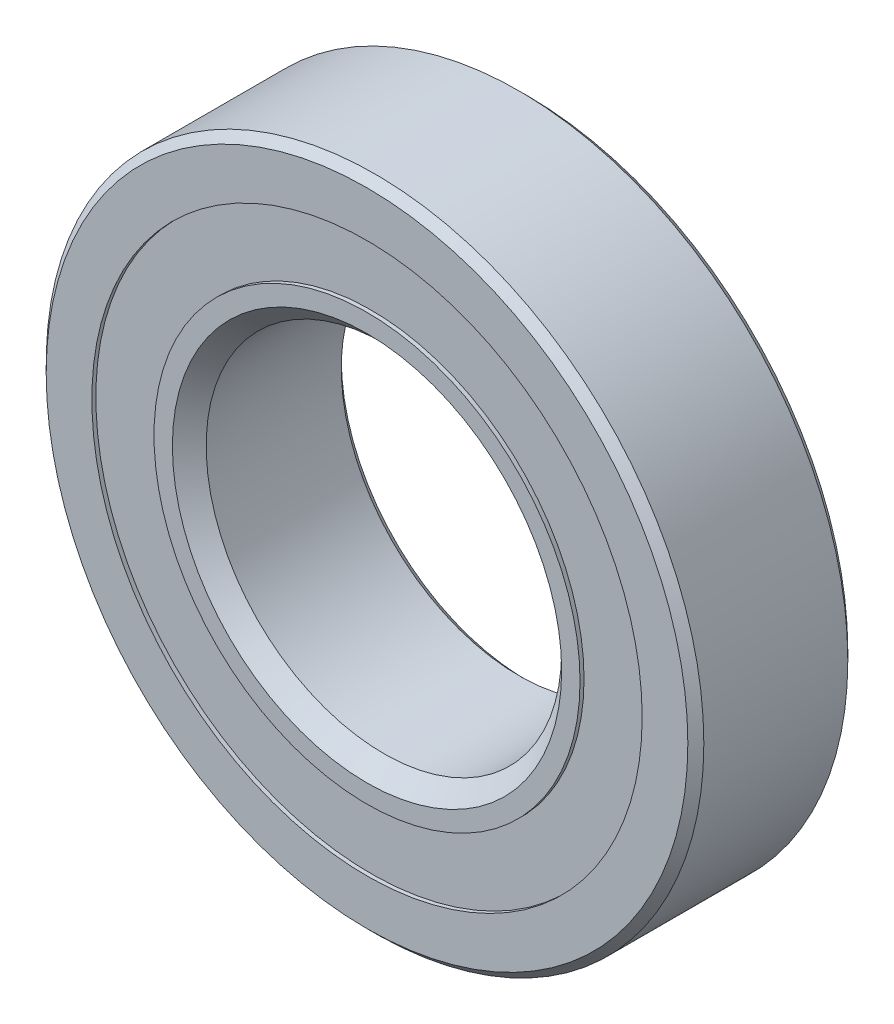
from build123d import *

# Parameters (mm, degrees)
CIRPATTERN1_COUNT = 12
SKETCH5_W         = 1.926640381
SKETCH5_H         = 3.495743751


with BuildPart() as part:
    # Sketch1 → Revolve1 (revolve)
    with BuildSketch(Plane(origin=(0, 0, 0), x_dir=(0, 0, -1), z_dir=(1, 0, 0))):
        with BuildLine():
            Line((4.05, 18.5), (-4.05, 18.5))
            Line((-4.05, 18.5), (-4.5, 18.05))
            Line((-4.5, 18.05), (-4.5, 15.480769231))
            Line((-4.5, 15.480769231), (-2, 15.480769231))
            ThreePointArc((-2, 15.480769231), (0, 16.598359619), (2, 15.480769231))
            Line((2, 15.480769231), (4.5, 15.480769231))
            Line((4.5, 15.480769231), (4.5, 18.05))
            Line((4.5, 18.05), (4.05, 18.5))
        make_face()
    revolve(axis=Axis((0, 0, 4.5), (0, 0, -1)))


with BuildPart() as body_2:
    # Sketch3 → Revolve3 (revolve)
    with BuildSketch(Plane(origin=(0, 0, 0), x_dir=(0, 0, -1), z_dir=(1, 0, 0))):
        with BuildLine():
            Line((-4.275, 11.76002548), (-3.465794711, 10.950820191))
            Line((-3.465794711, 10.950820191), (0, 10.950820191))
            Line((0, 10.950820191), (0, 11.901640381))
            ThreePointArc((0, 11.901640381), (1.145535713, 12.199990041), (2, 13.019230769))
            Line((2, 13.019230769), (4.5, 13.019230769))
            Line((4.5, 13.019230769), (4.5, 10.45))
            Line((4.5, 10.45), (4.05, 10))
            Line((4.05, 10), (-3.549179809, 10))
            Line((-3.549179809, 10), (-4.5, 10.950820191))
            Line((-4.5, 10.950820191), (-4.5, 11.98502548))
            Line((-4.5, 11.98502548), (-4.275, 11.98502548))
            Line((-4.275, 11.98502548), (-4.275, 11.76002548))
        make_face()
    revolve(axis=Axis((0, 0, 4.5), (0, 0, -1)))


with BuildPart() as body_3:
    # Sketch4 → Revolve4 (revolve)
    with BuildSketch(Plane(origin=(0, 0, 0), x_dir=(0, 0, -1), z_dir=(1, 0, 0))):
        with BuildLine():
            Line((-2.348359619, 14.25), (2.348359619, 14.25))
            ThreePointArc((2.348359619, 14.25), (0, 16.598359619), (-2.348359619, 14.25))
        make_face()
    revolve(axis=Axis((0, 14.25, 2.348359619), (0, 0, -1)))


with BuildPart() as cirpattern1_1:
    # CirPattern1: pattern copy
    add(body_3.part.rotate(Axis((0, 0, -4.5), (0, 0, 1)), 1 * 360 / CIRPATTERN1_COUNT))


with BuildPart() as cirpattern1_2:
    # CirPattern1: pattern copy
    add(body_3.part.rotate(Axis((0, 0, -4.5), (0, 0, 1)), 2 * 360 / CIRPATTERN1_COUNT))


with BuildPart() as cirpattern1_3:
    # CirPattern1: pattern copy
    add(body_3.part.rotate(Axis((0, 0, -4.5), (0, 0, 1)), 3 * 360 / CIRPATTERN1_COUNT))


with BuildPart() as cirpattern1_4:
    # CirPattern1: pattern copy
    add(body_3.part.rotate(Axis((0, 0, -4.5), (0, 0, 1)), 4 * 360 / CIRPATTERN1_COUNT))


with BuildPart() as cirpattern1_5:
    # CirPattern1: pattern copy
    add(body_3.part.rotate(Axis((0, 0, -4.5), (0, 0, 1)), 5 * 360 / CIRPATTERN1_COUNT))


with BuildPart() as cirpattern1_6:
    # CirPattern1: pattern copy
    add(body_3.part.rotate(Axis((0, 0, -4.5), (0, 0, 1)), 6 * 360 / CIRPATTERN1_COUNT))


with BuildPart() as cirpattern1_7:
    # CirPattern1: pattern copy
    add(body_3.part.rotate(Axis((0, 0, -4.5), (0, 0, 1)), 7 * 360 / CIRPATTERN1_COUNT))


with BuildPart() as cirpattern1_8:
    # CirPattern1: pattern copy
    add(body_3.part.rotate(Axis((0, 0, -4.5), (0, 0, 1)), 8 * 360 / CIRPATTERN1_COUNT))


with BuildPart() as cirpattern1_9:
    # CirPattern1: pattern copy
    add(body_3.part.rotate(Axis((0, 0, -4.5), (0, 0, 1)), 9 * 360 / CIRPATTERN1_COUNT))


with BuildPart() as cirpattern1_10:
    # CirPattern1: pattern copy
    add(body_3.part.rotate(Axis((0, 0, -4.5), (0, 0, 1)), 10 * 360 / CIRPATTERN1_COUNT))


with BuildPart() as cirpattern1_11:
    # CirPattern1: pattern copy
    add(body_3.part.rotate(Axis((0, 0, -4.5), (0, 0, 1)), 11 * 360 / CIRPATTERN1_COUNT))


with BuildPart() as body_15:
    # Sketch5 → Revolve5 (revolve)
    with BuildSketch(Plane(origin=(0, 0, 0), x_dir=(0, 0, -1), z_dir=(1, 0, 0))):
        with Locations((-3.31167981, 13.732897356)):
            Rectangle(SKETCH5_W, SKETCH5_H)
        with Locations((3.31167981, 13.732897356)):
            Rectangle(SKETCH5_W, SKETCH5_H)
    revolve(axis=Axis((0, 0, 4.5), (0, 0, -1)))


solid = Compound([part.part, body_2.part, body_3.part, cirpattern1_1.part, cirpattern1_2.part, cirpattern1_3.part, cirpattern1_4.part, cirpattern1_5.part, cirpattern1_6.part, cirpattern1_7.part, cirpattern1_8.part, cirpattern1_9.part, cirpattern1_10.part, cirpattern1_11.part, body_15.part])
